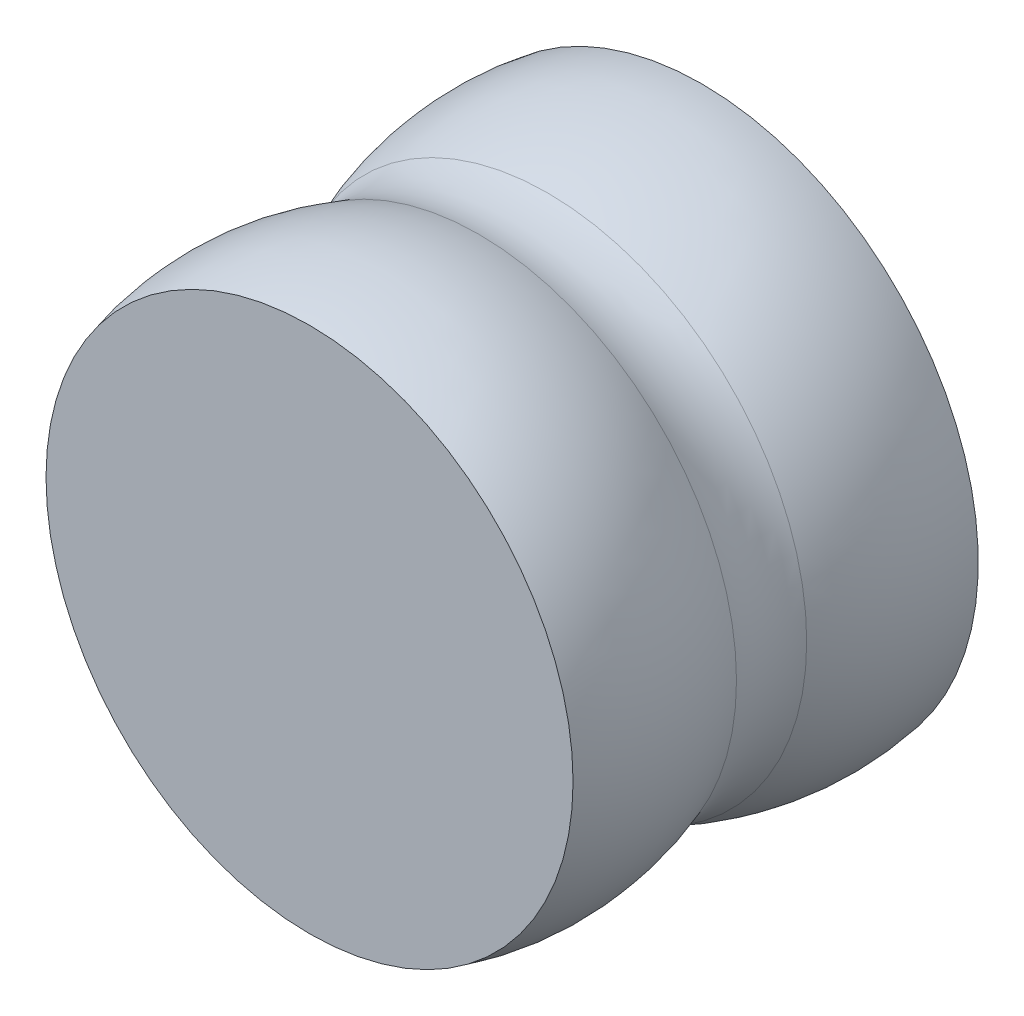
from build123d import *


with BuildPart() as part:
    # Sketch1 → Revolve1 (revolve)
    with BuildSketch(Plane(origin=(0, 0, 0), x_dir=(0, 0, -1), z_dir=(1, 0, 0))):
        with BuildLine():
            Line((-50.959835356, 0), (0, 0))
            Line((0, 0), (0, 34.862194457))
            ThreePointArc((0, 34.862194457), (-9.983164412, 35.191546696), (-19.660918939, 32.719075891))
            ThreePointArc((-19.660918939, 32.719075891), (-22.156838697, 31.96402236), (-24.751974583, 31.709089016))
            ThreePointArc((-24.751974583, 31.709089016), (-27.067794058, 31.911696967), (-29.31324853, 32.513364679))
            ThreePointArc((-29.31324853, 32.513364679), (-40.083090543, 34.583634671), (-50.959835356, 33.179377896))
            Line((-50.959835356, 33.179377896), (-50.959835356, 0))
        make_face()
        with BuildLine():
            ThreePointArc((-19.660918939, 32.719075891), (-9.983164412, 35.191546696), (0, 34.862194457))
            Line((0, 34.862194457), (0, 35.877187771))
            ThreePointArc((0, 35.877187771), (-10.179122164, 36.1760026), (-20.042663952, 33.643343571))
            ThreePointArc((-20.042663952, 33.643343571), (-22.351430988, 32.944906574), (-24.751974583, 32.709089016))
            ThreePointArc((-24.751974583, 32.709089016), (-26.89414588, 32.89650472), (-28.971228387, 33.4530573))
            ThreePointArc((-28.971228387, 33.4530573), (-39.904723407, 35.578313442), (-50.959835356, 34.220916375))
            Line((-50.959835356, 34.220916375), (-50.959835356, 33.179377896))
            ThreePointArc((-50.959835356, 33.179377896), (-40.083090543, 34.583634671), (-29.31324853, 32.513364679))
            ThreePointArc((-29.31324853, 32.513364679), (-27.067794058, 31.911696967), (-24.751974583, 31.709089016))
            ThreePointArc((-24.751974583, 31.709089016), (-22.156838697, 31.96402236), (-19.660918939, 32.719075891))
        make_face()
    revolve(axis=Axis((0, 0, 0), (0, 0, 1)))


solid = part.part
